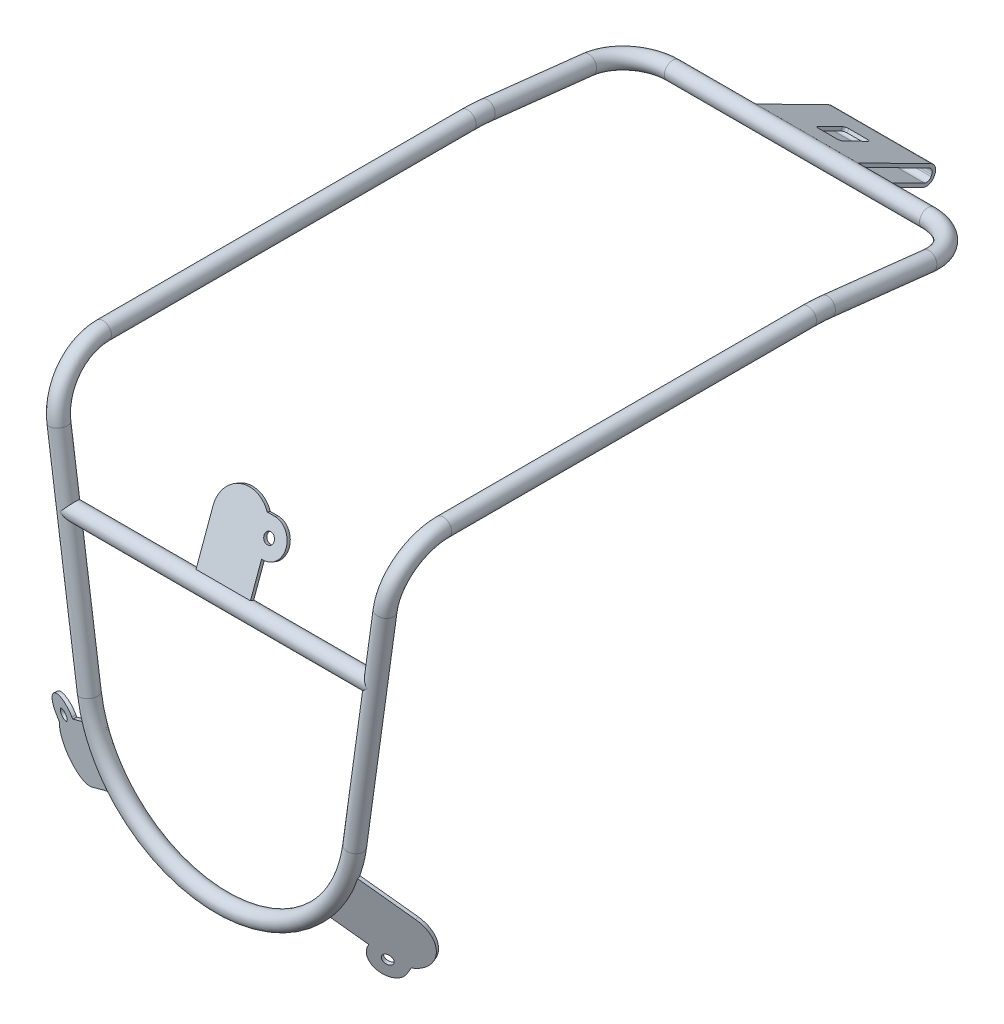
from build123d import *

# Parameters (mm, degrees)
SKETCH_1_R               = 5
SKETCH_8_R               = 5
SKETCH_9_R               = 3
EXTRUDE_1_DEPTH          = 1
PATTERN_CIRCULAR_2_COUNT = 3
EXTRUDE_2_DEPTH          = 30
EXTRUDE_2_DEPTH_BACK     = 30
CUT_EXTRUDE_1_DEPTH      = 5


with BuildPart() as part:
    # 扫描1: sweep along a curve in space
    with BuildLine() as sweep_1_path:
        Line((100, 0, -30), (100, 0, -244.461486186))
        ThreePointArc((100, -0.611626533, -255.504638794), (100, -0.153023714, -249.99152476), (100, 0, -244.461486186))
        Line((100, -0.611626533, -255.504638794), (100, -7.239211848, -315.152906633))
        ThreePointArc((75, -10, -340), (92.67766953, -9.191383872, -332.722454846), (100, -7.239211848, -315.152906633))
        Line((75, -10, -340), (-75, -10, -340))
        ThreePointArc((-75, -10, -340), (-92.67766953, -9.191383872, -332.722454846), (-100, -7.239211848, -315.152906633))
        Line((-100, -0.611626533, -255.504638794), (-100, -7.239211848, -315.152906633))
        ThreePointArc((-100, 0, -244.461486186), (-100, -0.153023714, -249.99152476), (-100, -0.611626533, -255.504638794))
        Line((-100, 0, -30), (-100, 0, -244.461486186))
        ThreePointArc((-100, 0, -30), (-98.791214708, -8.703254103, -8.786796564), (-95.872948862, -29.714768195, 0))
        Line((-95.872948862, -29.714768195, 0), (-77.989060596, -158.478763708, 0))
        ThreePointArc((-77.989060596, -158.478763708, 0), (0, -226.384626656, 0), (77.989060596, -158.478763708, 0))
        Line((95.872948862, -29.714768195, 0), (77.989060596, -158.478763708, 0))
        ThreePointArc((95.872948862, -29.714768195, 0), (98.791214708, -8.703254103, -8.786796564), (100, 0, -30))
    # 草图1 → 扫描1 (sweep)
    with BuildSketch(Plane.ZY):
        with Locations((-340, -10)):
            Circle(SKETCH_1_R)
    sweep(path=sweep_1_path.line)

    # 扫描5: sweep along a path in 草图2
    with BuildLine(Plane(origin=(0, -70, 0), x_dir=(1, 0, 0), z_dir=(0, 1, 0))) as sweep_5_path:
        Line((-90.260487496, 0), (90.260487496, 0))
    # 草图8 → 扫描5 (sweep)
    with BuildSketch(Plane(origin=(90.260487496, -70, 0), x_dir=(0, 0, -1), z_dir=(1, 0, 0))):
        with Locations((0, -0.015570491)):
            Circle(SKETCH_8_R)
    sweep(path=sweep_5_path.line)

    # 草图9 → 凸台-拉伸1 (add, symmetric)
    with BuildSketch(Plane(origin=(0, -8.188444491, -22.497566339), x_dir=(1, 0, 0), z_dir=(0, -0.3420201433256631, -0.9396926207859105))):
        with BuildLine():
            Line((-16, 65.778483455), (16, 65.778483455))
            Line((16, 65.778483455), (16, 41.778483455))
            Line((16, 41.778483455), (17, 41.778483455))
            ThreePointArc((17, 41.778483455), (27, 31.778483455), (17, 21.778483455))
            Line((17, 21.778483455), (12.489995997, 21.778483455))
            ThreePointArc((12.489995997, 21.778483455), (-5.299059542, 16.681464942), (-16, 31.778483455))
            Line((-16, 31.778483455), (-16, 65.778483455))
        make_face()
        with Locations((17, 31.778483455)):
            Circle(SKETCH_9_R, mode=Mode.SUBTRACT)
    extrude_1 = extrude(amount=EXTRUDE_1_DEPTH, both=True)

    # 阵列(圆周)2: 凸台-拉伸1 ×3 about axis
    pattern_circular_2_axis = Axis((0, -147.646949737, 0), (0, 0, 1))
    for i in range(1, PATTERN_CIRCULAR_2_COUNT):
        add(extrude_1.rotate(pattern_circular_2_axis, i * 360 / PATTERN_CIRCULAR_2_COUNT))

    # 草图14 → 凸台-拉伸2 (add, two sides: drawn at the far end of the back side and taken through both)
    with BuildSketch(Plane(origin=(0, 0, 0), x_dir=(0, 0, -1), z_dir=(1, 0, 0)).offset(-EXTRUDE_2_DEPTH_BACK)):
        with BuildLine():
            Line((340.55215763, -5.030581327), (386.778344879, -28.563260648))
            ThreePointArc((386.778344879, -28.563260648), (389.264711464, -31.472322721), (388.965820617, -35.287466913))
            Line((388.965820617, -35.287466913), (388.584357581, -36.036790078))
            ThreePointArc((388.584357581, -36.036790078), (385.675295508, -38.523156663), (381.860151316, -38.224265817))
            Line((381.860151316, -38.224265817), (361.741968678, -27.982565847))
            Line((361.741968678, -27.982565847), (362.649314783, -26.200229446))
            Line((362.649314783, -26.200229446), (382.767497421, -36.441929416))
            ThreePointArc((382.767497421, -36.441929416), (385.056583936, -36.621263924), (386.80202118, -35.129443973))
            Line((386.80202118, -35.129443973), (387.183484217, -34.380120807))
            ThreePointArc((387.183484217, -34.380120807), (387.362818724, -32.091034292), (385.870998774, -30.345597048))
            Line((385.870998774, -30.345597048), (339.644811525, -6.812917727))
            Line((339.644811525, -6.812917727), (340.55215763, -5.030581327))
        make_face()
    extrude(amount=EXTRUDE_2_DEPTH + EXTRUDE_2_DEPTH_BACK)

    # 草图15 → 切除-拉伸1 (cut)
    with BuildSketch(Plane(origin=(0, 133.689705139, -68.058326824), x_dir=(1, 0, 0), z_dir=(0, 0.8911682003552971, -0.4536730526221514))):
        with BuildLine():
            Line((5.5, 323.180408649), (-5.5, 323.180408649))
            ThreePointArc((-5.5, 323.180408649), (-6.914213562, 323.766195086), (-7.5, 325.180408649))
            Line((-7.5, 325.180408649), (-7.5, 341.180408649))
            ThreePointArc((-7.5, 341.180408649), (-6.914213562, 342.594622211), (-5.5, 343.180408649))
            Line((-5.5, 343.180408649), (5.5, 343.180408649))
            ThreePointArc((5.5, 343.180408649), (6.914213562, 342.594622211), (7.5, 341.180408649))
            Line((7.5, 341.180408649), (7.5, 325.180408649))
            ThreePointArc((7.5, 325.180408649), (6.914213562, 323.766195086), (5.5, 323.180408649))
        make_face()
    extrude(amount=-CUT_EXTRUDE_1_DEPTH, mode=Mode.SUBTRACT)


solid = part.part
